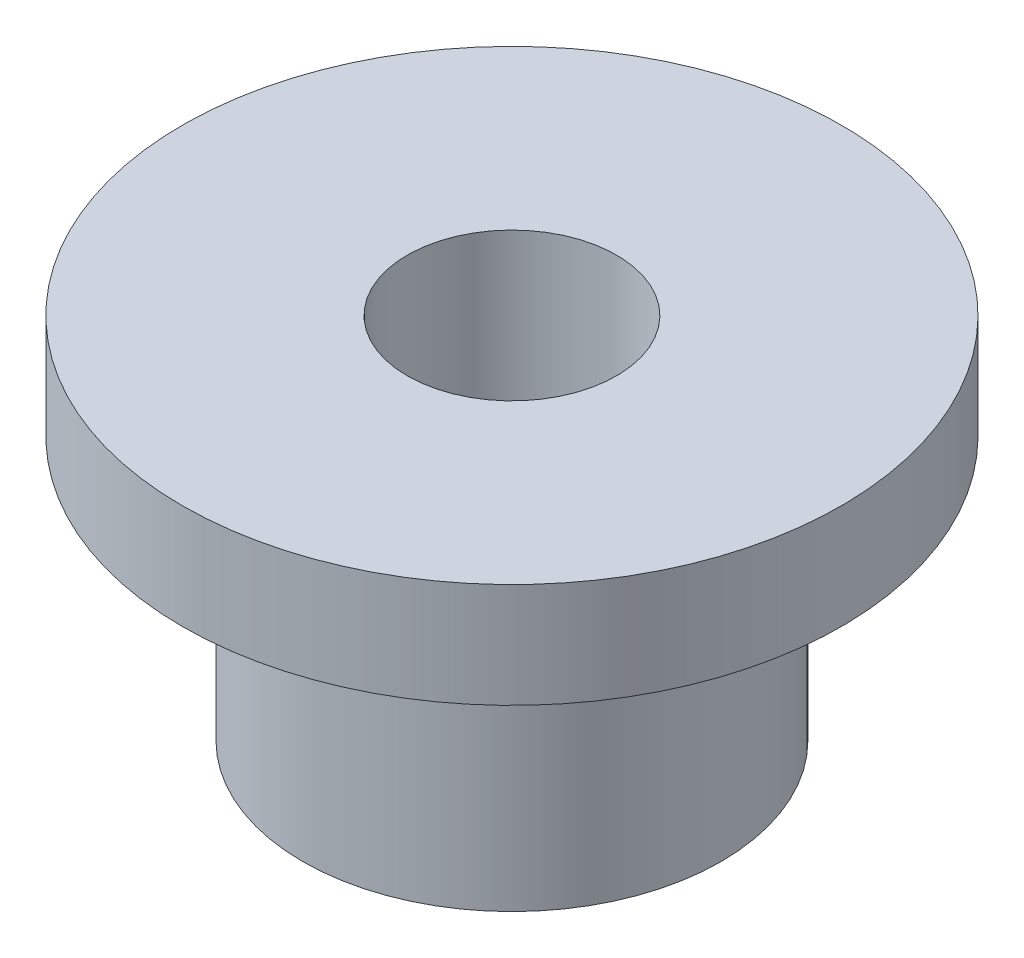
from build123d import *

# Parameters (mm, degrees)
SKETCH1_R           = 6.35
SKETCH1_R_2         = 3.175
BOSS_EXTRUDE1_DEPTH = 8
SKETCH2_R           = 10
SKETCH2_R_2         = 3.175
BOSS_EXTRUDE2_DEPTH = 3.175


with BuildPart() as part:
    # Sketch1 → Boss-Extrude1 (new body)
    with BuildSketch(Plane(origin=(0, 0, 0), x_dir=(1, 0, 0), z_dir=(0, 1, 0))):
        Circle(SKETCH1_R)
        Circle(SKETCH1_R_2, mode=Mode.SUBTRACT)
    extrude(amount=BOSS_EXTRUDE1_DEPTH)

    # Sketch2 → Boss-Extrude2 (add)
    with BuildSketch(Plane(origin=(0, 8, 0), x_dir=(1, 0, 0), z_dir=(0, 1, 0))):
        Circle(SKETCH2_R)
        Circle(SKETCH2_R_2, mode=Mode.SUBTRACT)
    extrude(amount=BOSS_EXTRUDE2_DEPTH)


solid = part.part
